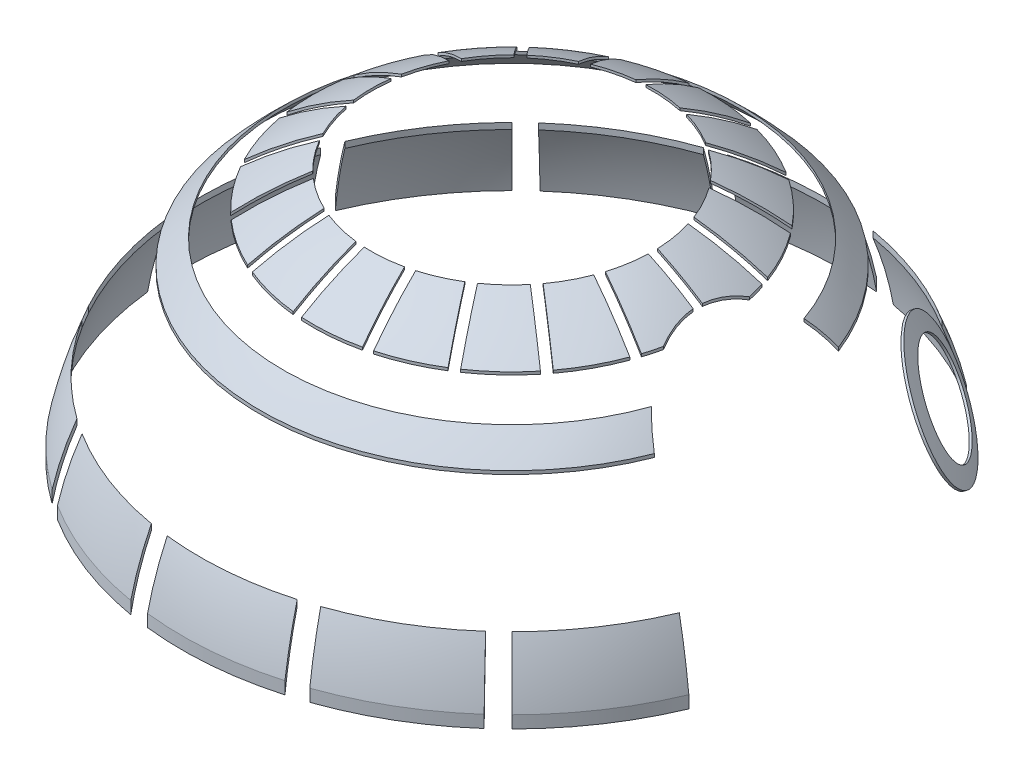
from build123d import *

# Parameters (mm, degrees)
SHELL_1_T           = 0.5
SKETCH_2_OUTSIDE_W  = 198.3
SKETCH_2_OUTSIDE_H  = 198.3
CUT_EXTRUDE_1_DEPTH = 255
SKETCH_4_R          = 15
SKETCH_4_R_2        = 11
CUT_EXTRUDE_2_DEPTH = 20


with BuildPart() as part:
    # 草图1 → 旋转1 (revolve)
    with BuildSketch(Plane.XY):
        with BuildLine():
            Line((-75, 129.232052778), (0, 129.232052778))
            Line((0, 129.232052778), (0, 204.232052778))
            ThreePointArc((0, 204.232052778), (-53.033008589, 182.265061367), (-75, 129.232052778))
        make_face()
    revolve(axis=Axis((0, 0, 0), (0, 1, 0)))

    # 抽壳1
    shell_1_openings = [part.faces().sort_by_distance(p)[0] for p in [
        (0, 129.232052778, -75),
        (0, 129.232052778, -75),
    ]]
    offset(amount=SHELL_1_T, openings=shell_1_openings, kind=Kind.INTERSECTION)

    # 草图2 outside → 切除-拉伸1 (cut)
    with BuildSketch(Plane(origin=(0, 0, 0), x_dir=(1, 0, 0), z_dir=(0, 1, 0))):
        Rectangle(SKETCH_2_OUTSIDE_W, SKETCH_2_OUTSIDE_H)
        with BuildLine():
            Line((64.567988979, -27.036545622), (68.257588349, -28.581491086))
            ThreePointArc((68.257588349, -28.581491086), (61.44952225, -41.230525285), (52.325901808, -52.325901808))
            Line((52.325901808, -52.325901808), (49.497474683, -49.497474683))
            ThreePointArc((49.497474683, -49.497474683), (58.127926453, -39.001848242), (64.567988979, -27.036545622))
        make_face(mode=Mode.SUBTRACT)
        with BuildLine():
            Line((23.561083333, -37.940390341), (16.433673676, -27.031077726))
            ThreePointArc((16.433673676, -27.031077726), (12.707454249, -28.970077667), (8.757185879, -30.398297469))
            Line((8.757185879, -30.398297469), (11.956164806, -43.030779568))
            ThreePointArc((11.956164806, -43.030779568), (17.940087638, -40.899280221), (23.561083333, -37.940390341))
        make_face(mode=Mode.SUBTRACT)
        with BuildLine():
            Line((34.603703454, -28.23440409), (24.320228497, -20.230454256))
            ThreePointArc((24.320228497, -20.230454256), (21.425498168, -23.274295302), (18.153008447, -25.907780258))
            Line((18.153008447, -25.907780258), (25.280418103, -36.817092873))
            ThreePointArc((25.280418103, -36.817092873), (30.248018784, -32.858107473), (34.603703454, -28.23440409))
        make_face(mode=Mode.SUBTRACT)
        with BuildLine():
            Line((25.581670875, -18.609753055), (35.865145833, -26.613702889))
            ThreePointArc((35.865145833, -26.613702889), (39.278107749, -21.256248934), (41.896475375, -15.468782053))
            Line((41.896475375, -15.468782053), (29.571309193, -11.237547158))
            ThreePointArc((29.571309193, -11.237547158), (27.82175691, -15.056381902), (25.581670875, -18.609753055))
        make_face(mode=Mode.SUBTRACT)
        with BuildLine():
            Line((-30.995520467, -32.153935654), (-22.169705549, -22.566544916))
            ThreePointArc((-22.169705549, -22.566544916), (-24.964105398, -19.430343157), (-27.318355609, -15.951559183))
            Line((-27.318355609, -15.951559183), (-38.778984215, -22.153741226))
            ThreePointArc((-38.778984215, -22.153741226), (-35.24374197, -27.431305456), (-30.995520467, -32.153935654))
        make_face(mode=Mode.SUBTRACT)
        with BuildLine():
            Line((-18.875731834, -40.475975773), (-13.641144595, -28.542318891))
            ThreePointArc((-13.641144595, -28.542318891), (-17.3024592, -26.483385342), (-20.65870895, -23.957515273))
            Line((-20.65870895, -23.957515273), (-29.484523869, -33.544906011))
            ThreePointArc((-29.484523869, -33.544906011), (-24.427208496, -37.388625973), (-18.875731834, -40.475975773))
        make_face(mode=Mode.SUBTRACT)
        with BuildLine():
            Line((9.965254244, -43.534946594), (6.766275318, -30.902464495))
            ThreePointArc((6.766275318, -30.902464495), (2.612360485, -31.526502601), (-1.587613659, -31.594687471))
            Line((-1.587613659, -31.594687471), (-2.663724467, -44.581413605))
            ThreePointArc((-2.663724467, -44.581413605), (3.688069627, -44.50838134), (9.965254244, -43.534946594))
        make_face(mode=Mode.SUBTRACT)
        with BuildLine():
            Line((-11.760370624, -29.367302844), (-16.994957862, -41.300959726))
            ThreePointArc((-16.994957862, -41.300959726), (-10.963607955, -43.294308722), (-4.710464769, -44.411815868))
            Line((-4.710464769, -44.411815868), (-3.634353961, -31.425089735))
            ThreePointArc((-3.634353961, -31.425089735), (-7.765823072, -30.666541793), (-11.760370624, -29.367302844))
        make_face(mode=Mode.SUBTRACT)
        with BuildLine():
            Line((-38.778984215, 22.153741226), (-27.318355609, 15.951559183))
            ThreePointArc((-27.318355609, 15.951559183), (-24.964105398, 19.430343157), (-22.169705549, 22.566544916))
            Line((-22.169705549, 22.566544916), (-30.995520467, 32.153935654))
            ThreePointArc((-30.995520467, 32.153935654), (-35.24374197, 27.431305456), (-38.778984215, 22.153741226))
        make_face(mode=Mode.SUBTRACT)
        with BuildLine():
            Line((-43.871139903, 8.361874829), (-31.01763455, 6.217004141))
            ThreePointArc((-31.01763455, 6.217004141), (-29.920503419, 10.271721798), (-28.295834907, 14.145335643))
            Line((-28.295834907, 14.145335643), (-39.756463513, 20.347517686))
            ThreePointArc((-39.756463513, 20.347517686), (-42.241069139, 14.501377352), (-43.871139903, 8.361874829))
        make_face(mode=Mode.SUBTRACT)
        with BuildLine():
            Line((-39.756463513, -20.347517686), (-28.295834907, -14.145335643))
            ThreePointArc((-28.295834907, -14.145335643), (-29.920503419, -10.271721798), (-31.01763455, -6.217004141))
            Line((-31.01763455, -6.217004141), (-43.871139903, -8.361874829))
            ThreePointArc((-43.871139903, -8.361874829), (-42.241069139, -14.501377352), (-39.756463513, -20.347517686))
        make_face(mode=Mode.SUBTRACT)
        with BuildLine():
            Line((-31.355671499, 4.191259766), (-44.209176852, 6.336130453))
            ThreePointArc((-44.209176852, 6.336130453), (-44.660921028, 0), (-44.209176852, -6.336130453))
            Line((-44.209176852, -6.336130453), (-31.355671499, -4.191259766))
            ThreePointArc((-31.355671499, -4.191259766), (-31.63455063, 0), (-31.355671499, 4.191259766))
        make_face(mode=Mode.SUBTRACT)
        with BuildLine():
            Line((11.956164806, 43.030779568), (8.757185879, 30.398297469))
            ThreePointArc((8.757185879, 30.398297469), (12.707454249, 28.970077667), (16.433673676, 27.031077726))
            Line((16.433673676, 27.031077726), (23.561083333, 37.940390341))
            ThreePointArc((23.561083333, 37.940390341), (17.940087638, 40.899280221), (11.956164806, 43.030779568))
        make_face(mode=Mode.SUBTRACT)
        with BuildLine():
            Line((-2.663724467, 44.581413605), (-1.587613659, 31.594687471))
            ThreePointArc((-1.587613659, 31.594687471), (2.612360485, 31.526502601), (6.766275318, 30.902464495))
            Line((6.766275318, 30.902464495), (9.965254244, 43.534946594))
            ThreePointArc((9.965254244, 43.534946594), (3.688069627, 44.50838134), (-2.663724467, 44.581413605))
        make_face(mode=Mode.SUBTRACT)
        with BuildLine():
            Line((-29.484523869, 33.544906011), (-20.65870895, 23.957515273))
            ThreePointArc((-20.65870895, 23.957515273), (-17.3024592, 26.483385342), (-13.641144595, 28.542318891))
            Line((-13.641144595, 28.542318891), (-18.875731834, 40.475975773))
            ThreePointArc((-18.875731834, 40.475975773), (-24.427208496, 37.388625973), (-29.484523869, 33.544906011))
        make_face(mode=Mode.SUBTRACT)
        with BuildLine():
            Line((-3.634353961, 31.425089735), (-4.710464769, 44.411815868))
            ThreePointArc((-4.710464769, 44.411815868), (-10.963607955, 43.294308722), (-16.994957862, 41.300959726))
            Line((-16.994957862, 41.300959726), (-11.760370624, 29.367302844))
            ThreePointArc((-11.760370624, 29.367302844), (-7.765823072, 30.666541793), (-3.634353961, 31.425089735))
        make_face(mode=Mode.SUBTRACT)
        with BuildLine():
            Line((25.280418103, 36.817092873), (18.153008447, 25.907780258))
            ThreePointArc((18.153008447, 25.907780258), (21.425498168, 23.274295302), (24.320228497, 20.230454256))
            Line((24.320228497, 20.230454256), (34.603703454, 28.23440409))
            ThreePointArc((34.603703454, 28.23440409), (30.248018784, 32.858107473), (25.280418103, 36.817092873))
        make_face(mode=Mode.SUBTRACT)
        with BuildLine():
            Line((29.571309193, 11.237547158), (41.896475375, 15.468782053))
            ThreePointArc((41.896475375, 15.468782053), (39.278107749, 21.256248934), (35.865145833, 26.613702889))
            Line((35.865145833, 26.613702889), (25.581670875, 18.609753055))
            ThreePointArc((25.581670875, 18.609753055), (27.82175691, 15.056381902), (29.571309193, 11.237547158))
        make_face(mode=Mode.SUBTRACT)
        with BuildLine():
            Line((30.238162324, -9.295070349), (42.563328506, -13.526305243))
            ThreePointArc((42.563328506, -13.526305243), (43.127573978, -11.602164878), (43.604883346, -9.654636993))
            ThreePointArc((43.604883346, -9.654636993), (42.262805024, -5.426028113), (41.688539591, -1.026877458))
            Line((41.688539591, -1.026877458), (31.617879692, -1.026877458))
            ThreePointArc((31.617879692, -1.026877458), (31.203096592, -5.2068759), (30.238162324, -9.295070349))
        make_face(mode=Mode.SUBTRACT)
        with BuildLine():
            Line((31.617879692, 1.026877458), (41.688539591, 1.026877458))
            ThreePointArc((41.688539591, 1.026877458), (42.262805024, 5.426028113), (43.604883346, 9.654636993))
            ThreePointArc((43.604883346, 9.654636993), (43.127573978, 11.602164878), (42.563328506, 13.526305243))
            Line((42.563328506, 13.526305243), (30.238162324, 9.295070349))
            ThreePointArc((30.238162324, 9.295070349), (31.203096592, 5.2068759), (31.617879692, 1.026877458))
        make_face(mode=Mode.SUBTRACT)
        with BuildLine():
            Line((46.443030426, -52.374086387), (49.096917879, -55.366891323))
            ThreePointArc((49.096917879, -55.366891323), (37.474852018, -63.80936817), (24.440650585, -69.847366443))
            Line((24.440650585, -69.847366443), (23.119534337, -66.071833122))
            ThreePointArc((23.119534337, -66.071833122), (35.449184342, -60.360213133), (46.443030426, -52.374086387))
        make_face(mode=Mode.SUBTRACT)
        with BuildLine():
            Line((19.11946011, -67.338297017), (20.212000688, -71.186199703))
            ThreePointArc((20.212000688, -71.186199703), (6.077827746, -73.749983118), (-8.285371232, -73.534703532))
            Line((-8.285371232, -73.534703532), (-7.837513327, -69.559854693))
            ThreePointArc((-7.837513327, -69.559854693), (5.749296516, -69.763497544), (19.11946011, -67.338297017))
        make_face(mode=Mode.SUBTRACT)
        with BuildLine():
            Line((-11.990953765, -68.965332072), (-12.676151123, -72.90620819))
            ThreePointArc((-12.676151123, -72.90620819), (-26.522984852, -69.083509426), (-39.370373662, -62.657590743))
            Line((-39.370373662, -62.657590743), (-37.242245356, -59.270693946))
            ThreePointArc((-37.242245356, -59.270693946), (-25.089309995, -65.349265673), (-11.990953765, -68.965332072))
        make_face(mode=Mode.SUBTRACT)
        with BuildLine():
            Line((-40.726412187, -56.932937306), (-43.053635741, -60.18624801))
            ThreePointArc((-43.053635741, -60.18624801), (-53.870595016, -50.734199438), (-62.657590743, -39.370373662))
            Line((-62.657590743, -39.370373662), (-59.270693946, -37.242245356))
            ThreePointArc((-59.270693946, -37.242245356), (-50.958670961, -47.991810279), (-40.726412187, -56.932937306))
        make_face(mode=Mode.SUBTRACT)
        with BuildLine():
            Line((-61.3955052, -33.624276071), (-64.903819783, -35.545663275))
            ThreePointArc((-64.903819783, -35.545663275), (-70.548473158, -22.336359037), (-73.534703532, -8.285371232))
            Line((-73.534703532, -8.285371232), (-69.559854693, -7.837513327))
            ThreePointArc((-69.559854693, -7.837513327), (-66.735042177, -21.128988279), (-61.3955052, -33.624276071))
        make_face(mode=Mode.SUBTRACT)
        with BuildLine():
            Line((-69.904465441, -3.655914584), (-73.899006323, -3.864823989))
            ThreePointArc((-73.899006323, -3.864823989), (-73.253360971, 10.485471208), (-69.847366443, 24.440650585))
            Line((-69.847366443, 24.440650585), (-66.071833122, 23.119534337))
            ThreePointArc((-66.071833122, 23.119534337), (-69.293719837, 9.91868898), (-69.904465441, -3.655914584))
        make_face(mode=Mode.SUBTRACT)
        with BuildLine():
            Line((-64.567988979, 27.036545622), (-68.257588349, 28.581491086))
            ThreePointArc((-68.257588349, 28.581491086), (-61.44952225, 41.230525285), (-52.325901808, 52.325901808))
            Line((-52.325901808, 52.325901808), (-49.497474683, 49.497474683))
            ThreePointArc((-49.497474683, 49.497474683), (-58.127926453, 39.001848242), (-64.567988979, 27.036545622))
        make_face(mode=Mode.SUBTRACT)
        with BuildLine():
            Line((-46.443030426, 52.374086387), (-49.096917879, 55.366891323))
            ThreePointArc((-49.096917879, 55.366891323), (-37.474852018, 63.80936817), (-24.440650585, 69.847366443))
            Line((-24.440650585, 69.847366443), (-23.119534337, 66.071833122))
            ThreePointArc((-23.119534337, 66.071833122), (-35.449184342, 60.360213133), (-46.443030426, 52.374086387))
        make_face(mode=Mode.SUBTRACT)
        with BuildLine():
            Line((-19.11946011, 67.338297017), (-20.212000688, 71.186199703))
            ThreePointArc((-20.212000688, 71.186199703), (-6.077827746, 73.749983118), (8.285371232, 73.534703532))
            Line((8.285371232, 73.534703532), (7.837513327, 69.559854693))
            ThreePointArc((7.837513327, 69.559854693), (-5.749296516, 69.763497544), (-19.11946011, 67.338297017))
        make_face(mode=Mode.SUBTRACT)
        with BuildLine():
            Line((11.990953765, 68.965332072), (12.676151123, 72.90620819))
            ThreePointArc((12.676151123, 72.90620819), (26.522984852, 69.083509426), (39.370373662, 62.657590743))
            Line((39.370373662, 62.657590743), (37.242245356, 59.270693946))
            ThreePointArc((37.242245356, 59.270693946), (25.089309995, 65.349265673), (11.990953765, 68.965332072))
        make_face(mode=Mode.SUBTRACT)
        Polygon((36.307091523, 53.036028144), (53.54474529, 70.273681911), (77.689029414, 36.817092873), (59.180573, 26.613702889), align=None, mode=Mode.SUBTRACT)
        with BuildLine():
            ThreePointArc((48.42853851, 17.107647086), (-51.361414808, 0), (48.42853851, -17.107647086))
            ThreePointArc((48.42853851, -17.107647086), (50.417327859, -19.009474003), (52.602908082, -20.68143925))
            ThreePointArc((52.602908082, -20.68143925), (-56.522454548, 0), (52.602908082, 20.68143925))
            ThreePointArc((52.602908082, 20.68143925), (50.417327859, 19.009474003), (48.42853851, 17.107647086))
        make_face(mode=Mode.SUBTRACT)
    extrude(amount=CUT_EXTRUDE_1_DEPTH, mode=Mode.SUBTRACT)

    # 草图4 → 切除-拉伸2 (cut)
    with BuildSketch(Plane(origin=(92.049608502, 49.643764162, -76.505791025), x_dir=(0.55019062, 0.220875653, 0.805297602), z_dir=(-0.71037332, -0.383115215, 0.590417207))):
        Polygon((39.817400951, 72.237429602), (0.441654741, 89.850798338), (13.490049789, 138.241211391), (50.941633837, 126.37536298), align=None)
        with Locations((28.544214022, 115.908737338)):
            Circle(SKETCH_4_R, mode=Mode.SUBTRACT)
        with Locations((28.544214022, 115.908737338)):
            Circle(SKETCH_4_R_2)
    extrude(amount=CUT_EXTRUDE_2_DEPTH, mode=Mode.SUBTRACT)


solid = part.part
